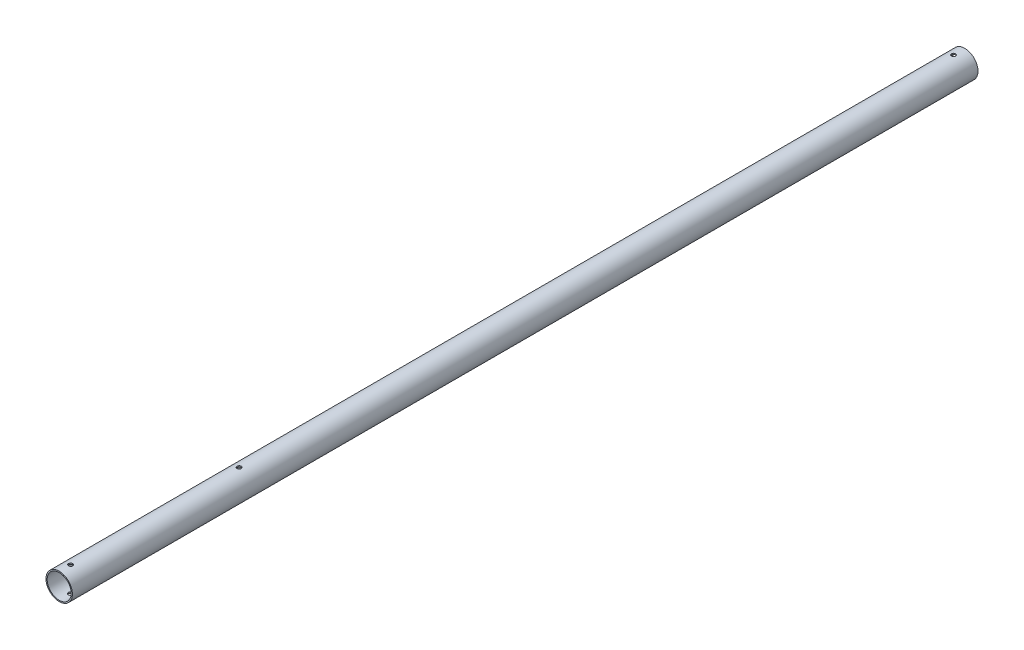
from build123d import *

# Parameters (mm, degrees)
SKETCH2_R               = 17.5
SKETCH2_R_2             = 15.9125
BOSS_EXTRUDE1_DEPTH     = 600
SKETCH5_W               = 2.75
SKETCH5_H               = 17.5
MIRROR2_COPY_1_SKETCH_W = 2.75
MIRROR2_COPY_1_SKETCH_H = 17.5
SKETCH6_R               = 2.75
CUT_EXTRUDE1_DEPTH      = 18.5000001
CUT_EXTRUDE1_DEPTH_BACK = 18.5000001


with BuildPart() as part:
    # Sketch2 → Boss-Extrude1 (new body, symmetric)
    with BuildSketch(Plane.XY):
        Circle(SKETCH2_R)
        Circle(SKETCH2_R_2, mode=Mode.SUBTRACT)
    extrude(amount=BOSS_EXTRUDE1_DEPTH, both=True)

    # Sketch5 → M5 Clearance Hole1 (revolve, cut)
    with BuildSketch(Plane(origin=(0, 0, -585), x_dir=(0, 0, -1), z_dir=(1, 0, 0))):
        with Locations((1.375, 8.75)):
            Rectangle(SKETCH5_W, SKETCH5_H)
    m5_clearance_hole1 = revolve(axis=Axis((0, -6.35, -585), (0, 1, 0)), mode=Mode.SUBTRACT)

    # Mirror1: M5 Clearance Hole1 across plane
    add(m5_clearance_hole1.mirror(Plane.ZX), mode=Mode.SUBTRACT)

    # Mirror2: M5 Clearance Hole1 across plane
    add(m5_clearance_hole1.mirror(Plane.XY), mode=Mode.SUBTRACT)

    # Mirror2 copy 1 sketch → Mirror2 copy 1 (revolve, cut)
    with BuildSketch(Plane(origin=(0, 0, 585), x_dir=(0, 0, 1), z_dir=(1, 0, 0))):
        with Locations((1.375, 8.75)):
            Rectangle(MIRROR2_COPY_1_SKETCH_W, MIRROR2_COPY_1_SKETCH_H)
    revolve(axis=Axis((0, 6.35, 585), (0, -1, 0)), mode=Mode.SUBTRACT)

    # Sketch6 → Cut-Extrude1 (cut, two sides)
    with BuildSketch(Plane(origin=(0, 0, 0), x_dir=(1, 0, 0), z_dir=(0, 1, 0))) as cut_extrude1_sk:
        with Locations((0, -361.65)):
            Circle(SKETCH6_R)
    extrude(amount=CUT_EXTRUDE1_DEPTH, mode=Mode.SUBTRACT)
    extrude(cut_extrude1_sk.sketch, amount=-CUT_EXTRUDE1_DEPTH_BACK, mode=Mode.SUBTRACT)


solid = part.part
